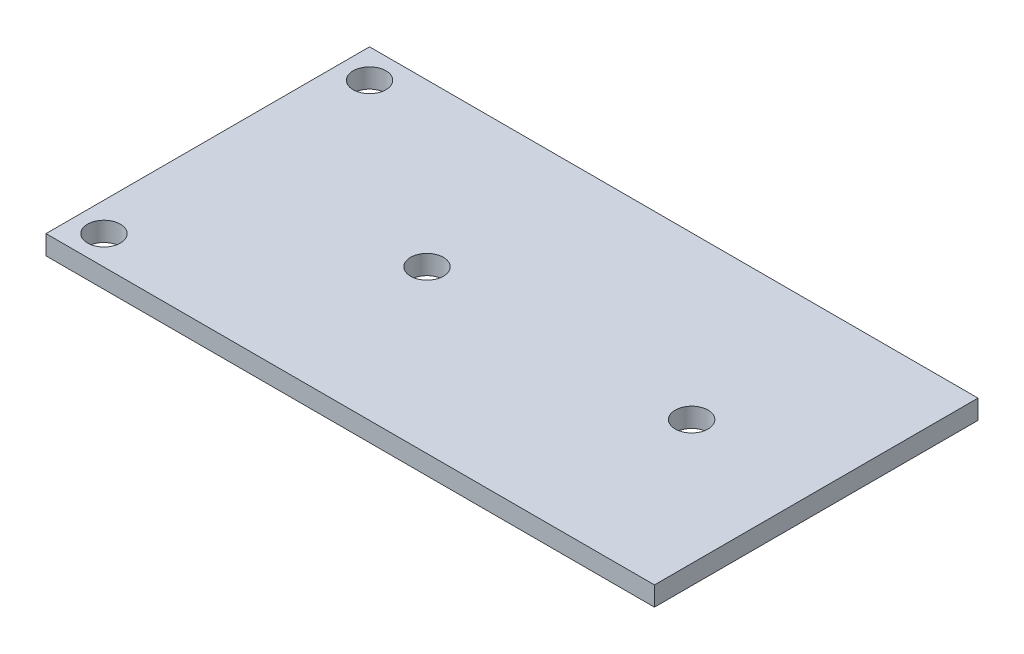
from build123d import *

# Parameters (mm, degrees)
SKETCH1_W            = 65
SKETCH1_H            = 33.5
BOSS_EXTRUDE1_DEPTH  = 2
M3_CLEARANCE_HOLE1_D = 3.4
M3_CLEARANCE_HOLE2_D = 3.4
SKETCH6_W            = 2
SKETCH6_H            = 33.5
CUT_EXTRUDE1_DEPTH   = 3


with BuildPart() as part:
    # Sketch1 → Boss-Extrude1 (new body)
    with BuildSketch(Plane(origin=(0, 0, 0), x_dir=(1, 0, 0), z_dir=(0, 1, 0))):
        with Locations((-39.686085356, 13.7444519)):
            Rectangle(SKETCH1_W, SKETCH1_H)
    extrude(amount=BOSS_EXTRUDE1_DEPTH)

    # M3 Clearance Hole1 (through all)
    with Locations(Plane(origin=(0, 2, 0), x_dir=(1, 0, 0), z_dir=(0, 1, 0))):
        with Locations((-67.186085356, 27.4944519), (-67.186085356, -0.0055481)):
            Hole(M3_CLEARANCE_HOLE1_D / 2)

    # M3 Clearance Hole2 (through all)
    with Locations(Plane(origin=(-47.486085356, 2, -13.7444519), x_dir=(0, 0, 1), z_dir=(0, 1, 0))):
        with Locations((0, 0), (0, 27.4)):
            Hole(M3_CLEARANCE_HOLE2_D / 2)

    # Sketch6 → Cut-Extrude1 (cut, through all)
    with BuildSketch(Plane.XZ):
        with Locations((-71.186085356, -13.7444519)):
            Rectangle(SKETCH6_W, SKETCH6_H)
    extrude(amount=-CUT_EXTRUDE1_DEPTH, mode=Mode.SUBTRACT)


solid = part.part
